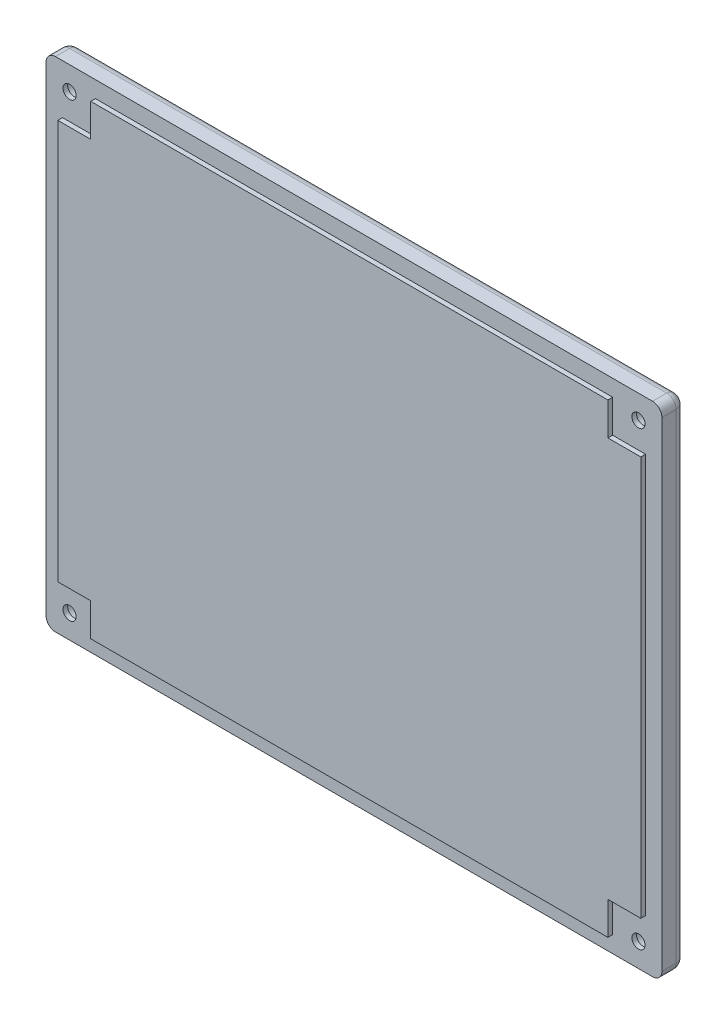
from build123d import *

# Parameters (mm, degrees)
SKETCH1_W               = 131
SKETCH1_H               = 106
BOSS_EXTRUDE1_DEPTH     = 5
SKETCH6_R               = 2
CUT_EXTRUDE1_DEPTH      = 4
SKETCH7_R               = 1.4
CUT_EXTRUDE2_DEPTH      = 2.8
MIRROR2_COPY_1_SKETCH_R = 2
MIRROR2_COPY_1_DEPTH    = 4
MIRROR2_COPY_2_SKETCH_R = 1.4
MIRROR2_COPY_2_DEPTH    = 2.8
SKETCH10_W              = 40
SKETCH10_H              = 66
CUT_EXTRUDE5_DEPTH      = 1
FILLET1_R               = 2
SKETCH8_W               = 110
SKETCH8_H               = 99
BOSS_EXTRUDE2_DEPTH     = 1
SKETCH11_W              = 7
SKETCH11_H              = 85
BOSS_EXTRUDE3_DEPTH     = 1


with BuildPart() as part:
    # Sketch1 → Boss-Extrude1 (new body)
    with BuildSketch(Plane.XY):
        with Locations((65.5, 53)):
            Rectangle(SKETCH1_W, SKETCH1_H)
    extrude(amount=BOSS_EXTRUDE1_DEPTH)

    # Sketch6 → Cut-Extrude1 (cut)
    with BuildSketch(Plane(origin=(0, 0, 0), x_dir=(-1, 0, 0), z_dir=(0, 0, -1))):
        with Locations((-5, 5)):
            Circle(SKETCH6_R)
    cut_extrude1 = extrude(amount=-CUT_EXTRUDE1_DEPTH, mode=Mode.SUBTRACT)

    # Sketch7 → Cut-Extrude2 (cut)
    with BuildSketch(Plane(origin=(0, 0, 4), x_dir=(-1, 0, 0), z_dir=(0, 0, -1))):
        with Locations((-5, 5)):
            Circle(SKETCH7_R)
    cut_extrude2 = extrude(amount=-CUT_EXTRUDE2_DEPTH, mode=Mode.SUBTRACT)

    # Mirror1: Cut-Extrude1, Cut-Extrude2 across plane
    add(cut_extrude1.mirror(Plane.ZY.offset(-65.5)), mode=Mode.SUBTRACT)
    add(cut_extrude2.mirror(Plane.ZY.offset(-65.5)), mode=Mode.SUBTRACT)

    # Mirror2: Cut-Extrude1, Cut-Extrude2 across plane
    add(cut_extrude1.mirror(Plane(origin=(0, 53, 0), x_dir=(0, 0, 1), z_dir=(0, -1, 0))), mode=Mode.SUBTRACT)
    add(cut_extrude2.mirror(Plane(origin=(0, 53, 0), x_dir=(0, 0, 1), z_dir=(0, -1, 0))), mode=Mode.SUBTRACT)

    # Mirror2 copy 1 sketch → Mirror2 copy 1 (cut)
    with BuildSketch(Plane(origin=(131, 106, 0), x_dir=(1, 0, 0), z_dir=(0, 0, -1))):
        with Locations((-5, 5)):
            Circle(MIRROR2_COPY_1_SKETCH_R)
    extrude(amount=-MIRROR2_COPY_1_DEPTH, mode=Mode.SUBTRACT)

    # Mirror2 copy 2 sketch → Mirror2 copy 2 (cut)
    with BuildSketch(Plane(origin=(131, 106, 4), x_dir=(1, 0, 0), z_dir=(0, 0, -1))):
        with Locations((-5, 5)):
            Circle(MIRROR2_COPY_2_SKETCH_R)
    extrude(amount=-MIRROR2_COPY_2_DEPTH, mode=Mode.SUBTRACT)

    # Sketch10 → Cut-Extrude5 (cut)
    with BuildSketch(Plane(origin=(0, 0, 0), x_dir=(-1, 0, 0), z_dir=(0, 0, -1))):
        with Locations((-81, 53)):
            Rectangle(SKETCH10_W, SKETCH10_H)
    extrude(amount=-CUT_EXTRUDE5_DEPTH, mode=Mode.SUBTRACT)

    # Fillet1
    fillet1_edges = [part.edges().sort_by_distance(p)[0] for p in [
        (65.5, 106, 0),
        (131, 53, 0),
        (65.5, 0, 0),
        (0, 53, 0),
        (0, 106, 2.5),
        (131, 106, 2.5),
        (131, 0, 2.5),
        (0, 0, 2.5),
    ]]
    fillet(fillet1_edges, radius=FILLET1_R)

    # Sketch8 → Boss-Extrude2 (add)
    with BuildSketch(Plane.XY.offset(5)):
        with Locations((65.5, 53)):
            Rectangle(SKETCH8_W, SKETCH8_H)
    extrude(amount=BOSS_EXTRUDE2_DEPTH)

    # Sketch11 → Boss-Extrude3 (add)
    with BuildSketch(Plane.XY.offset(5)):
        with Locations((7, 53)):
            Rectangle(SKETCH11_W, SKETCH11_H)
    boss_extrude3 = extrude(amount=BOSS_EXTRUDE3_DEPTH)

    # Mirror3: Boss-Extrude3 across plane
    add(boss_extrude3.mirror(Plane.ZY.offset(-65.5)))


solid = part.part
